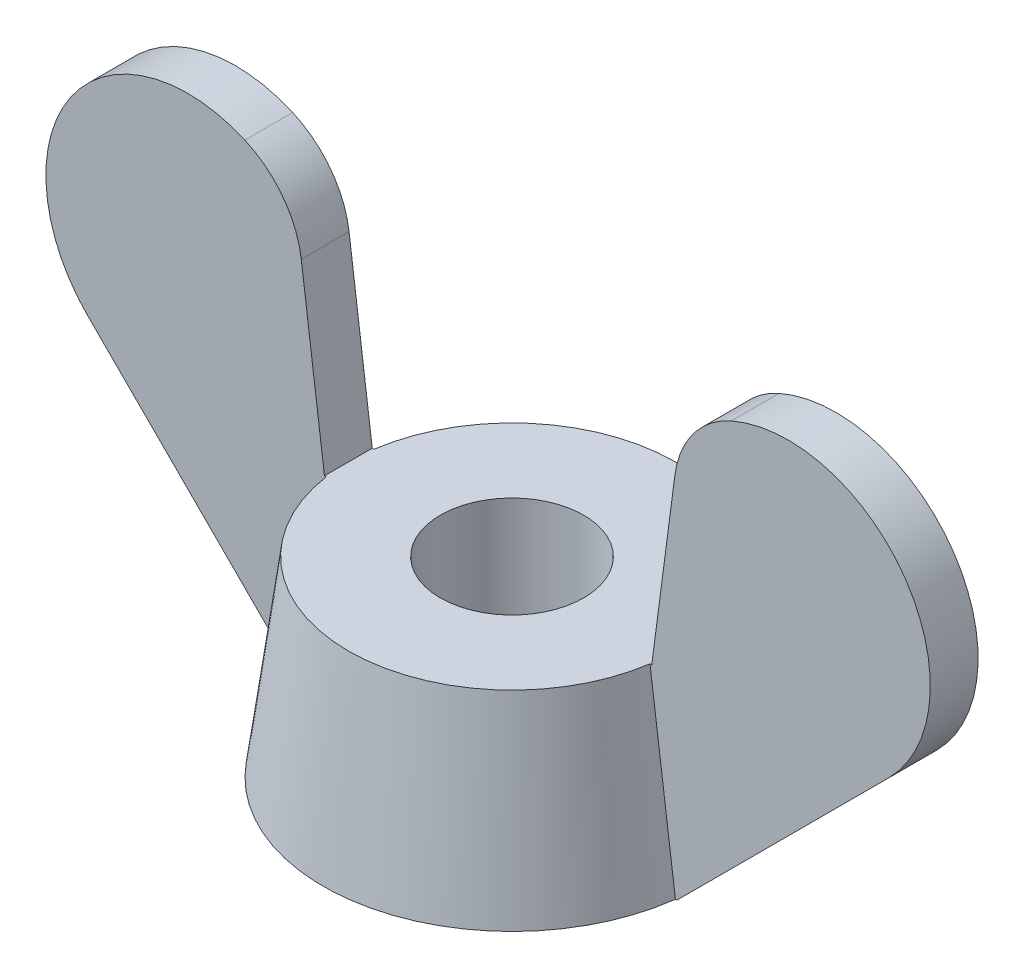
from build123d import *

# Parameters (mm, degrees)
SKETCH_1_R          = 3.95
EXTRUDE_1_DEPTH     = 4
EXTRUDE_1_TAPER     = 7.5
SKETCH_2_R          = 1.5
CUT_EXTRUDE_1_DEPTH = 4
EXTRUDE_2_DEPTH     = 0.5


with BuildPart() as part:
    # 草图1 → 凸台-拉伸1 (new body)
    with BuildSketch(Plane(origin=(0, 0, 0), x_dir=(1, 0, 0), z_dir=(0, 1, 0))):
        Circle(SKETCH_1_R)
    extrude(amount=EXTRUDE_1_DEPTH, taper=EXTRUDE_1_TAPER)

    # 草图2 → 切除-拉伸1 (cut)
    with BuildSketch(Plane(origin=(0, 0, 0), x_dir=(1, 0, 0), z_dir=(0, 1, 0))):
        Circle(SKETCH_2_R)
    extrude(amount=CUT_EXTRUDE_1_DEPTH, mode=Mode.SUBTRACT)

    # 草图3 → 凸台-拉伸2 (add, symmetric)
    with BuildSketch(Plane.XY):
        with BuildLine():
            Line((8.380151519, 4.430151519), (3.95, 0))
            Line((3.95, 0), (1.95, 0))
            Line((1.95, 0), (1.95, 4))
            Line((1.95, 4), (3.42339001, 4))
            Line((3.42339001, 4), (3.907794349, 7.679416256))
            ThreePointArc((3.907794349, 7.679416256), (4.291558837, 8.619529341), (5.087532952, 9.250015662))
            ThreePointArc((5.087532952, 9.250015662), (8.73241738, 8.205380502), (8.380151519, 4.430151519))
        make_face()
        with BuildLine():
            Line((-1.95, 4), (-1.95, 0))
            Line((-1.95, 0), (-3.95, 0))
            Line((-3.95, 0), (-8.380151519, 4.430151519))
            ThreePointArc((-8.380151519, 4.430151519), (-8.73241738, 8.205380502), (-5.087532952, 9.250015662))
            ThreePointArc((-5.087532952, 9.250015662), (-4.291558837, 8.619529341), (-3.907794349, 7.679416256))
            Line((-3.907794349, 7.679416256), (-3.42339001, 4))
            Line((-3.42339001, 4), (-1.95, 4))
        make_face()
    extrude(amount=EXTRUDE_2_DEPTH, both=True)


solid = part.part
